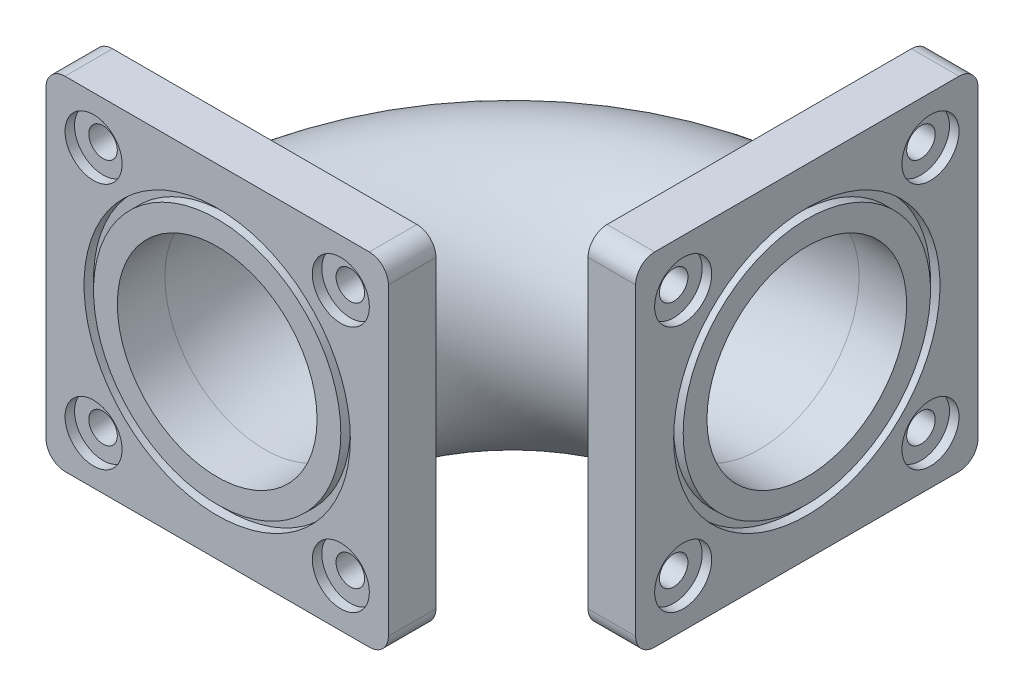
from build123d import *

# Parameters (mm, degrees)
SKETCH3_R                              = 13
SKETCH3_R_2                            = 10.5
REVOLVE2_ANGLE                         = 90
SKETCH5_W                              = 36
SKETCH5_H                              = 36
SKETCH5_R                              = 10.5
BOSS_EXTRUDE3_DEPTH                    = 5
SKETCH6_R                              = 14
SKETCH6_R_2                            = 13
CUT_EXTRUDE1_DEPTH                     = 1
FILLET1_R                              = 2
FILLET2_R                              = 2
CBORE_FOR_M5_HEX_HEAD_BOLT1_AT_2_COUNT = 2
CBORE_FOR_M5_HEX_HEAD_BOLT1_AT_2_PITCH = 26
CBORE_FOR_M5_HEX_HEAD_BOLT1_AT_3_COUNT = 2
CBORE_FOR_M5_HEX_HEAD_BOLT1_AT_3_PITCH = 36.769552622
CBORE_FOR_M5_HEX_HEAD_BOLT1_AT_4_COUNT = 2
CBORE_FOR_M5_HEX_HEAD_BOLT1_AT_4_PITCH = 26
FILLET1_OF_MIRROR1_R                   = 2
FILLET2_OF_MIRROR1_R                   = 2


with BuildPart() as part:
    # Sketch3 → Revolve2 (revolve)
    with BuildSketch(Plane.XY):
        with Locations((-26, 0)):
            Circle(SKETCH3_R)
        with Locations((-26, 0)):
            Circle(SKETCH3_R_2, mode=Mode.SUBTRACT)
    revolve(axis=Axis((0, 20.536946156, 0), (0, -1, 0)), revolution_arc=REVOLVE2_ANGLE)

    # Sketch5 → Boss-Extrude3 (add)
    with BuildSketch(Plane.XY):
        with Locations((-26, 0)):
            Rectangle(SKETCH5_W, SKETCH5_H)
        with Locations(Location((-26, 0, 0), (0, 0, 180))):
            Circle(SKETCH5_R, mode=Mode.SUBTRACT)
    boss_extrude3 = extrude(amount=BOSS_EXTRUDE3_DEPTH)

    # Sketch6 → Cut-Extrude1 (cut)
    with BuildSketch(Plane.XY.offset(5)):
        with Locations((-26, 0)):
            Circle(SKETCH6_R)
        with Locations((-26, 0)):
            Circle(SKETCH6_R_2, mode=Mode.SUBTRACT)
    cut_extrude1 = extrude(amount=-CUT_EXTRUDE1_DEPTH, mode=Mode.SUBTRACT)

    # Fillet1
    fillet1_edges = [part.edges().sort_by_distance(p)[0] for p in [
        (-44, 18, 2.5),
        (-44, -18, 2.5),
        (-8, -18, 2.5),
        (-8, 18, 2.5),
    ]]
    fillet(fillet1_edges, radius=FILLET1_R)

    # Fillet2
    fillet2_edges = [part.edges().sort_by_distance(p)[0] for p in [
        (-39, 0, 0),
    ]]
    fillet(fillet2_edges, radius=FILLET2_R)

    # Sketch8 → CBORE for M5 Hex Head Bolt1 (revolve, cut)
    with BuildSketch(Plane(origin=(-39, -13, 5), x_dir=(0, -1, 0), z_dir=(1, 0, 0))):
        Polygon((0, 0), (0, 11), (1.5, 10.098709071), (1.5, 1), (3, 1), (3, 0), align=None)
    cbore_for_m5_hex_head_bolt1 = revolve(axis=Axis((-39, -13, 11.35), (0, 0, -1)), mode=Mode.SUBTRACT)

    # CBORE for M5 Hex Head Bolt1 at 2: CBORE for M5 Hex Head Bolt1 ×2
    with Locations(*[(0, i * CBORE_FOR_M5_HEX_HEAD_BOLT1_AT_2_PITCH, 0) for i in range(1, CBORE_FOR_M5_HEX_HEAD_BOLT1_AT_2_COUNT)]):
        add(cbore_for_m5_hex_head_bolt1, mode=Mode.SUBTRACT)

    # CBORE for M5 Hex Head Bolt1 at 3: CBORE for M5 Hex Head Bolt1 ×2
    with Locations(*[Vector(0.7071067811865476, 0.7071067811865476, 0) * (i * CBORE_FOR_M5_HEX_HEAD_BOLT1_AT_3_PITCH) for i in range(1, CBORE_FOR_M5_HEX_HEAD_BOLT1_AT_3_COUNT)]):
        add(cbore_for_m5_hex_head_bolt1, mode=Mode.SUBTRACT)

    # CBORE for M5 Hex Head Bolt1 at 4: CBORE for M5 Hex Head Bolt1 ×2
    with Locations(*[(i * CBORE_FOR_M5_HEX_HEAD_BOLT1_AT_4_PITCH, 0, 0) for i in range(1, CBORE_FOR_M5_HEX_HEAD_BOLT1_AT_4_COUNT)]):
        add(cbore_for_m5_hex_head_bolt1, mode=Mode.SUBTRACT)

    # Mirror1: Boss-Extrude3, Cut-Extrude1, CBORE for M5 Hex Head Bolt1 across plane
    add(boss_extrude3.mirror(Plane(origin=(0, 0, 0), x_dir=(0.7071067811865464, 0, 0.7071067811865487), z_dir=(-0.7071067811865489, 0, 0.7071067811865462))))
    add(cut_extrude1.mirror(Plane(origin=(0, 0, 0), x_dir=(0.7071067811865464, 0, 0.7071067811865487), z_dir=(-0.7071067811865489, 0, 0.7071067811865462))), mode=Mode.SUBTRACT)
    add(cbore_for_m5_hex_head_bolt1.mirror(Plane(origin=(0, 0, 0), x_dir=(0.7071067811865464, 0, 0.7071067811865487), z_dir=(-0.7071067811865489, 0, 0.7071067811865462))), mode=Mode.SUBTRACT)

    # Mirror1 copy 1 sketch → Mirror1 copy 1 (revolve, cut)
    with BuildSketch(Plane(origin=(5, 13, -39), x_dir=(0, -1, 0), z_dir=(0, 0, 1))):
        Polygon((0, 0), (0, -11), (1.5, -10.098709071), (1.5, -1), (3, -1), (3, 0), align=None)
    revolve(axis=Axis((11.35, 13, -39), (1, 0, 0)), mode=Mode.SUBTRACT)

    # Mirror1 copy 2 sketch → Mirror1 copy 2 (revolve, cut)
    with BuildSketch(Plane(origin=(5, 13, -13), x_dir=(0, -1, 0), z_dir=(0, 0, 1))):
        Polygon((0, 0), (0, -11), (1.5, -10.098709071), (1.5, -1), (3, -1), (3, 0), align=None)
    revolve(axis=Axis((11.35, 13, -13), (1, 0, 0)), mode=Mode.SUBTRACT)

    # Mirror1 copy 3 sketch → Mirror1 copy 3 (revolve, cut)
    with BuildSketch(Plane(origin=(5, -13, -13), x_dir=(0, -1, 0), z_dir=(0, 0, 1))):
        Polygon((0, 0), (0, -11), (1.5, -10.098709071), (1.5, -1), (3, -1), (3, 0), align=None)
    revolve(axis=Axis((11.35, -13, -13), (1, 0, 0)), mode=Mode.SUBTRACT)

    # Fillet1 of Mirror1
    fillet1_of_mirror1_edges = [part.edges().sort_by_distance(p)[0] for p in [
        (2.5, 18, -44),
        (2.5, -18, -44),
        (2.5, -18, -8),
        (2.5, 18, -8),
    ]]
    fillet(fillet1_of_mirror1_edges, radius=FILLET1_OF_MIRROR1_R)

    # Fillet2 of Mirror1
    fillet2_of_mirror1_edges = [part.edges().sort_by_distance(p)[0] for p in [
        (0, 0, -39),
    ]]
    fillet(fillet2_of_mirror1_edges, radius=FILLET2_OF_MIRROR1_R)


solid = part.part
